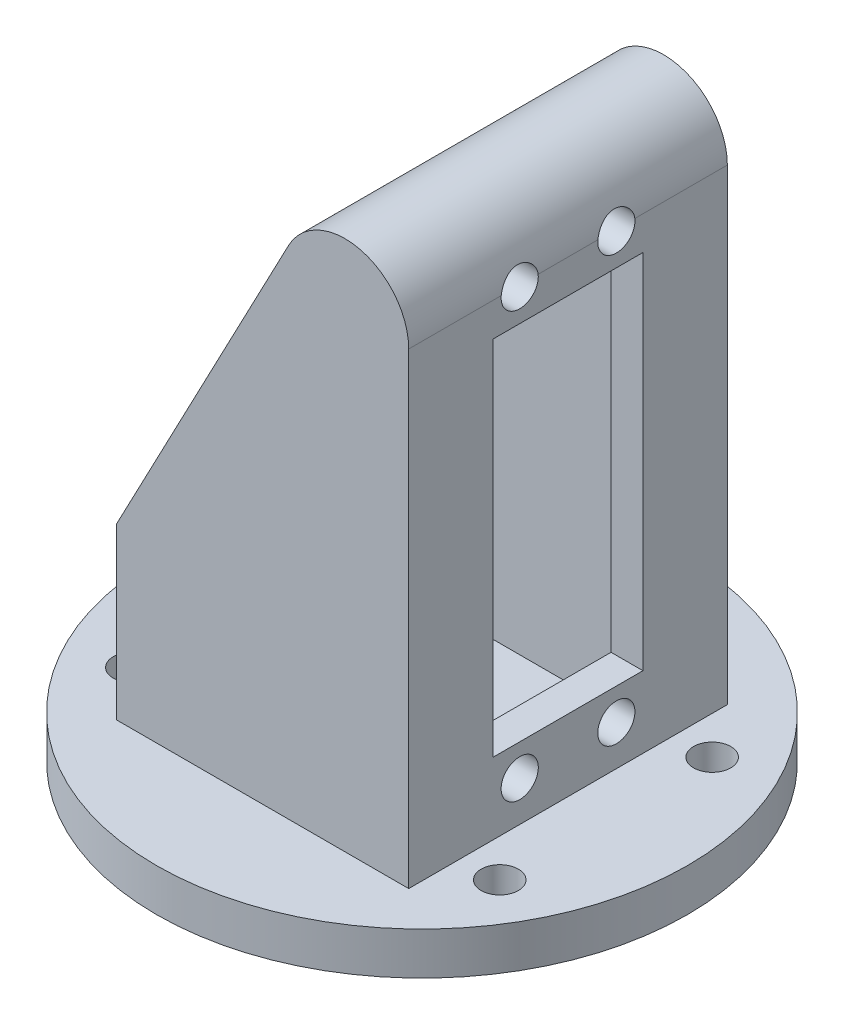
from build123d import *

# Parameters (mm, degrees)
SKETCH1_R           = 25
SKETCH1_R_2         = 1.75
BOSS_EXTRUDE1_DEPTH = 4
SKETCH2_W           = 27.5
SKETCH2_H           = 30
BOSS_EXTRUDE2_DEPTH = 50
CUT_EXTRUDE1_DEPTH  = 41
SKETCH4_W           = 17
SKETCH4_H           = 46
CUT_EXTRUDE2_DEPTH  = 24.5
CUT_EXTRUDE3_REACH  = 16.25
SKETCH5_R           = 1.75
SKETCH5_W           = 14.1
SKETCH5_H           = 34.1


with BuildPart() as part:
    # Sketch1 → Boss-Extrude1 (new body)
    with BuildSketch(Plane(origin=(0, 0, 0), x_dir=(1, 0, 0), z_dir=(0, 1, 0))):
        Circle(SKETCH1_R)
        with Locations((-17.320508076, 10)):
            Circle(SKETCH1_R_2, mode=Mode.SUBTRACT)
        with Locations((17.320508076, 10)):
            Circle(SKETCH1_R_2, mode=Mode.SUBTRACT)
        with Locations((17.320508076, -10)):
            Circle(SKETCH1_R_2, mode=Mode.SUBTRACT)
        with Locations((-17.320508076, -10)):
            Circle(SKETCH1_R_2, mode=Mode.SUBTRACT)
    extrude(amount=BOSS_EXTRUDE1_DEPTH)

    # Sketch2 → Boss-Extrude2 (add)
    with BuildSketch(Plane(origin=(0, 4, 0), x_dir=(1, 0, 0), z_dir=(0, 1, 0))):
        Rectangle(SKETCH2_W, SKETCH2_H)
    extrude(amount=BOSS_EXTRUDE2_DEPTH)

    # Sketch3 → Cut-Extrude1 (cut, through all)
    with BuildSketch(Plane.XY.offset(15)):
        with BuildLine():
            ThreePointArc((2.439273587, 50.792164924), (4.647822502, 53.135805173), (7.75, 54))
            Line((7.75, 54), (-13.75, 54))
            Line((-13.75, 54), (-13.75, 20))
            Line((-13.75, 20), (2.439273587, 50.792164924))
        make_face()
        with BuildLine():
            Line((13.75, 48), (13.75, 54))
            Line((13.75, 54), (7.75, 54))
            ThreePointArc((7.75, 54), (11.992640687, 52.242640687), (13.75, 48))
        make_face()
    extrude(amount=-CUT_EXTRUDE1_DEPTH, mode=Mode.SUBTRACT)

    # Sketch4 → Cut-Extrude2 (cut)
    with BuildSketch(Plane.ZY.offset(13.75)):
        with Locations((0, 27.792164924)):
            Rectangle(SKETCH4_W, SKETCH4_H)
    extrude(amount=-CUT_EXTRUDE2_DEPTH, mode=Mode.SUBTRACT)

    # Sketch5 → Cut-Extrude3 (cut, up to next)
    with BuildSketch(Plane.ZY.offset(-10.75), mode=Mode.PRIVATE) as cut_extrude3_sk1:
        with Locations((-4.55, 47.802164924)):
            Circle(SKETCH5_R)
    cut_extrude3_tool1 = extrude(cut_extrude3_sk1.sketch, amount=-CUT_EXTRUDE3_REACH, mode=Mode.PRIVATE) & part.part
    add(cut_extrude3_tool1.solids().sort_by_distance((10.75, 47.802165, -4.55))[0], mode=Mode.SUBTRACT)
    # Sketch5 → Cut-Extrude3 (cut, up to next)
    with BuildSketch(Plane.ZY.offset(-10.75), mode=Mode.PRIVATE) as cut_extrude3_sk2:
        with Locations((-4.55, 7.782164924)):
            Circle(SKETCH5_R)
    cut_extrude3_tool2 = extrude(cut_extrude3_sk2.sketch, amount=-CUT_EXTRUDE3_REACH, mode=Mode.PRIVATE) & part.part
    add(cut_extrude3_tool2.solids().sort_by_distance((10.75, 7.782165, -4.55))[0], mode=Mode.SUBTRACT)
    # Sketch5 → Cut-Extrude3 (cut, up to next)
    with BuildSketch(Plane.ZY.offset(-10.75), mode=Mode.PRIVATE) as cut_extrude3_sk3:
        with Locations((4.55, 7.782164924)):
            Circle(SKETCH5_R)
    cut_extrude3_tool3 = extrude(cut_extrude3_sk3.sketch, amount=-CUT_EXTRUDE3_REACH, mode=Mode.PRIVATE) & part.part
    add(cut_extrude3_tool3.solids().sort_by_distance((10.75, 7.782165, 4.55))[0], mode=Mode.SUBTRACT)
    # Sketch5 → Cut-Extrude3 (cut, up to next)
    with BuildSketch(Plane.ZY.offset(-10.75), mode=Mode.PRIVATE) as cut_extrude3_sk4:
        with Locations((4.55, 47.802164924)):
            Circle(SKETCH5_R)
    cut_extrude3_tool4 = extrude(cut_extrude3_sk4.sketch, amount=-CUT_EXTRUDE3_REACH, mode=Mode.PRIVATE) & part.part
    add(cut_extrude3_tool4.solids().sort_by_distance((10.75, 47.802165, 4.55))[0], mode=Mode.SUBTRACT)
    # Sketch5 → Cut-Extrude3 (cut, up to next)
    with BuildSketch(Plane.ZY.offset(-10.75), mode=Mode.PRIVATE) as cut_extrude3_sk5:
        with Locations((0, 27.792164924)):
            Rectangle(SKETCH5_W, SKETCH5_H)
    cut_extrude3_tool5 = extrude(cut_extrude3_sk5.sketch, amount=-CUT_EXTRUDE3_REACH, mode=Mode.PRIVATE) & part.part
    add(cut_extrude3_tool5.solids().sort_by_distance((10.75, 27.792165, 0))[0], mode=Mode.SUBTRACT)


solid = part.part
